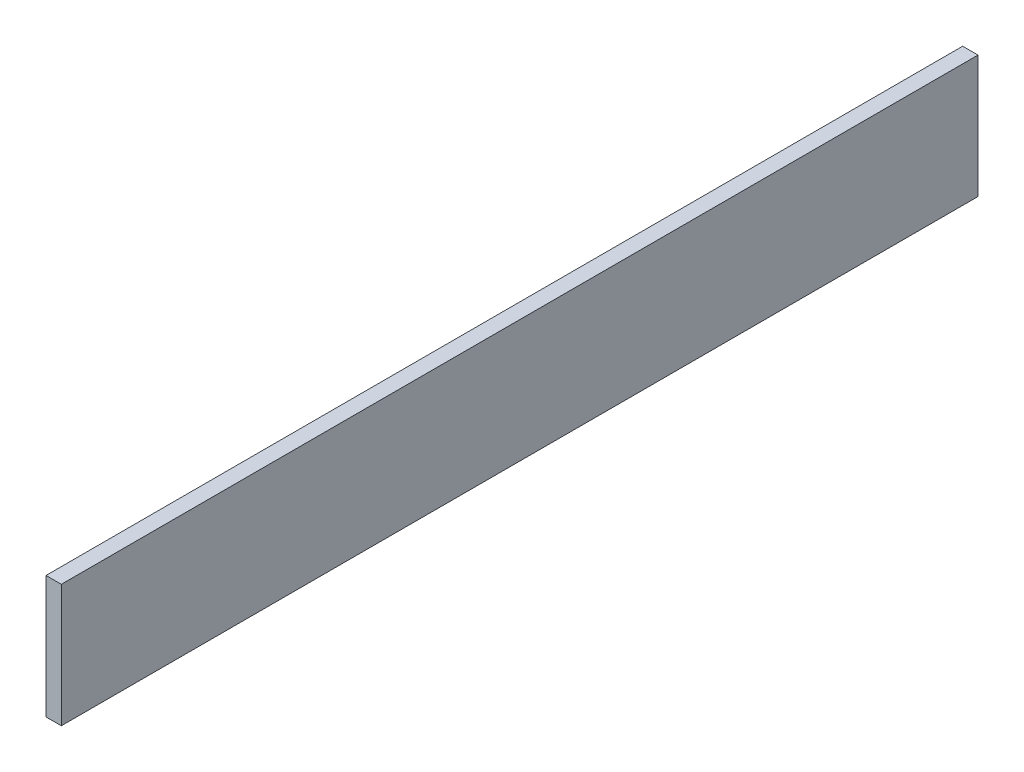
from build123d import *

# Parameters (mm, degrees)
SKETCH1_W           = 189.992
SKETCH1_H           = 25.4
BOSS_EXTRUDE2_DEPTH = 3.175


with BuildPart() as part:
    # Sketch1 → Boss-Extrude2 (new body)
    with BuildSketch(Plane(origin=(0, 0, 0), x_dir=(0, 0, -1), z_dir=(1, 0, 0))):
        with Locations((93.902857562, -1.104952208)):
            Rectangle(SKETCH1_W, SKETCH1_H)
    extrude(amount=BOSS_EXTRUDE2_DEPTH)


solid = part.part
